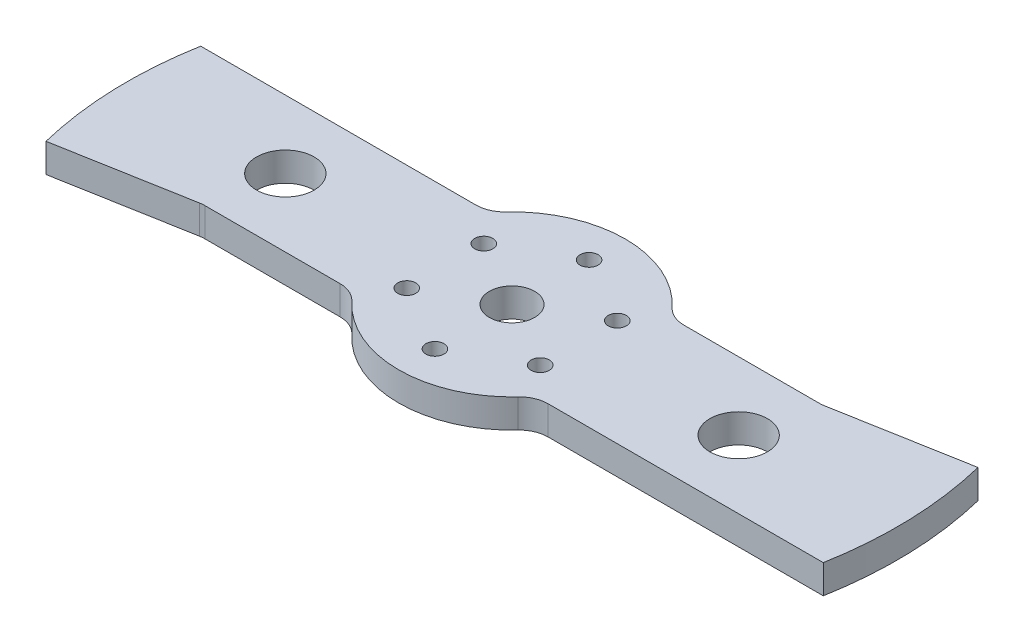
from build123d import *

# Parameters (mm, degrees)
CROQUIS1_R              = 5
CROQUIS1_R_2            = 2
SALIENTE_EXTRUIR1_DEPTH = 6.35
REDONDEO1_R             = 6.35
CROQUIS2_R              = 6.35
CORTAR_EXTRUIR1_DEPTH   = 7.35


with BuildPart() as part:
    # Croquis1 → Saliente-Extruir1 (new body)
    with BuildSketch(Plane(origin=(0, 0, 0), x_dir=(1, 0, 0), z_dir=(0, 1, 0))):
        with BuildLine():
            Line((-22.956480566, 15), (-83.666002653, 15))
            ThreePointArc((-83.666002653, 15), (-85, 0), (-83.666002653, -15))
            ThreePointArc((-83.666002653, -15), (-83.151528449, -17.630181979), (-82.554391371, -20.242837383))
            Line((-82.554391371, -20.242837383), (-53.31124161, -15))
            Line((-53.31124161, -15), (-22.956480566, -15))
            ThreePointArc((-22.956480566, -15), (-20.420534839, -15.528361119), (-18.306603323, -17.025518341))
            ThreePointArc((-18.306603323, -17.025518341), (0, -25), (18.306603323, -17.025518341))
            ThreePointArc((18.306603323, -17.025518341), (20.420534839, -15.528361119), (22.956480566, -15))
            Line((22.956480566, -15), (83.666002653, -15))
            ThreePointArc((83.666002653, -15), (85, 0), (83.666002653, 15))
            ThreePointArc((83.666002653, 15), (83.151528449, 17.630181979), (82.554391371, 20.242837383))
            Line((82.554391371, 20.242837383), (53.31124161, 15))
            Line((53.31124161, 15), (22.956480566, 15))
            ThreePointArc((22.956480566, 15), (20.420534839, 15.528361119), (18.306603323, 17.025518341))
            ThreePointArc((18.306603323, 17.025518341), (0, 25), (-18.306603323, 17.025518341))
            ThreePointArc((-18.306603323, 17.025518341), (-20.420534839, 15.528361119), (-22.956480566, 15))
        make_face()
        Circle(CROQUIS1_R, mode=Mode.SUBTRACT)
        with Locations((0, 17)):
            Circle(CROQUIS1_R_2, mode=Mode.SUBTRACT)
        with Locations((14.722431864, 8.5)):
            Circle(CROQUIS1_R_2, mode=Mode.SUBTRACT)
        with Locations((14.722431864, -8.5)):
            Circle(CROQUIS1_R_2, mode=Mode.SUBTRACT)
        with Locations((0, -17)):
            Circle(CROQUIS1_R_2, mode=Mode.SUBTRACT)
        with Locations((-14.722431864, -8.5)):
            Circle(CROQUIS1_R_2, mode=Mode.SUBTRACT)
        with Locations((-14.722431864, 8.5)):
            Circle(CROQUIS1_R_2, mode=Mode.SUBTRACT)
    extrude(amount=SALIENTE_EXTRUIR1_DEPTH)

    # Redondeo1
    redondeo1_edges = [part.edges().sort_by_distance(p)[0] for p in [
        (53.31124161, 3.175, -15),
        (-53.31124161, 3.175, 15),
    ]]
    fillet(redondeo1_edges, radius=REDONDEO1_R)

    # Croquis2 → Cortar-Extruir1 (cut, through all)
    with BuildSketch(Plane(origin=(0, 6.35, 0), x_dir=(1, 0, 0), z_dir=(0, 1, 0))):
        with Locations((-50, 0)):
            Circle(CROQUIS2_R)
        with Locations((50, 0)):
            Circle(CROQUIS2_R)
    extrude(amount=-CORTAR_EXTRUIR1_DEPTH, mode=Mode.SUBTRACT)


solid = part.part
